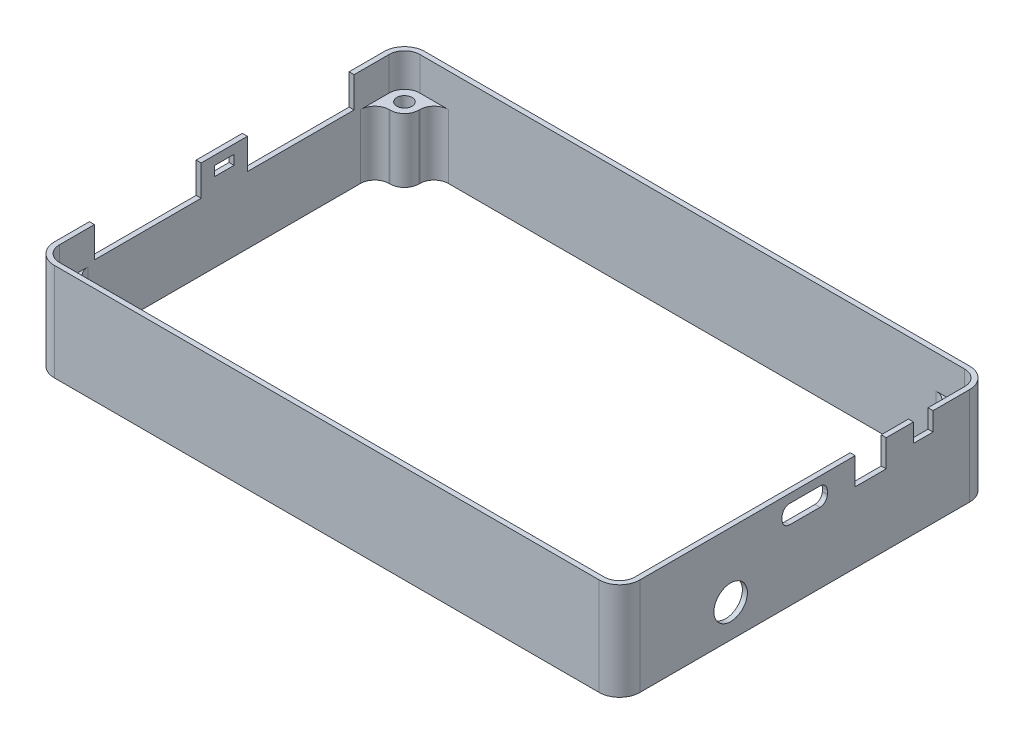
from build123d import *

# Parameters (mm, degrees)
WALLS_DEPTH         = 7
WALLS_DEPTH_BACK    = 13.4
SKETCH11_R          = 1.6
BOSS_EXTRUDE4_DEPTH = 13.4
MOVE_FACE7_BY       = 0.2
MOVE_FACE7_2_BY     = 0.2
MOVE_FACE7_3_BY     = 0.2
MOVE_FACE7_4_BY     = 0.2
MOVE_FACE7_5_BY     = 0.2
MOVE_FACE7_6_BY     = 0.2
MOVE_FACE7_7_BY     = 0.2
MOVE_FACE7_8_BY     = 0.2
FILLET1_R           = 3
SKETCH8_R           = 3.25
SKETCH8_W           = 6
SKETCH8_H           = 5.22
CUT_EXTRUDE3_DEPTH  = 1.05
CUT_EXTRUDE4_REACH  = 131.18
SKETCH10_W          = 20.32
SKETCH10_H          = 5.4
SKETCH10_W_2        = 3.6
SKETCH10_H_2        = 1.5
MOVE_FACE3_BY       = 0.25
MOVE_FACE3_2_BY     = 0.25
MOVE_FACE3_3_BY     = 0.25
MOVE_FACE4_BY       = 0.25
MOVE_FACE4_2_BY     = 0.25
MOVE_FACE4_3_BY     = 0.25
MOVE_FACE4_4_BY     = 0.25
MOVE_FACE4_5_BY     = 0.25
MOVE_FACE4_6_BY     = 0.25
MOVE_FACE4_7_BY     = 0.25
MOVE_FACE4_8_BY     = 0.25
MOVE_FACE4_9_BY     = 0.25
MOVE_FACE4_10_BY    = 0.25
MOVE_FACE4_11_BY    = 0.25
MOVE_FACE4_12_BY    = 0.25
MOVE_FACE4_13_BY    = 0.25
MOVE_FACE1_BY       = 1
MOVE_FACE1_2_BY     = 1
MOVE_FACE1_3_BY     = 1
MOVE_FACE1_4_BY     = 1
MOVE_FACE1_5_BY     = 1
MOVE_FACE1_6_BY     = 1
MOVE_FACE2_BY       = 0.25
MOVE_FACE2_2_BY     = 0.25
MOVE_FACE2_3_BY     = 0.25
MOVE_FACE2_4_BY     = 0.25
SKETCH4_R           = 2.15
BOTTOM_LID_DEPTH    = 3
SKETCH5_R           = 5.5
SKETCH5_R_2         = 1.6
SKETCH5_W           = 7.62
SKETCH5_H           = 2.54
TOP_LID_DEPTH       = 1.6
MOVE_FACE5_BY       = 0.25
MOVE_FACE5_2_BY     = 0.25
MOVE_FACE5_3_BY     = 0.25
MOVE_FACE5_4_BY     = 0.25


with BuildPart() as part:
    # Sketch2 → Walls (new, two sides)
    with BuildSketch(Plane(origin=(0, 0, 0), x_dir=(1, 0, 0), z_dir=(0, 1, 0))) as walls_sk:
        with BuildLine():
            Line((-61.25, -34.5), (-61.25, 34.5))
            ThreePointArc((-61.25, 34.5), (-60.00520382, 37.50520382), (-57, 38.75))
            Line((-57, 38.75), (57, 38.75))
            ThreePointArc((57, 38.75), (60.00520382, 37.50520382), (61.25, 34.5))
            Line((61.25, 34.5), (61.25, -34.5))
            ThreePointArc((61.25, -34.5), (60.00520382, -37.50520382), (57, -38.75))
            Line((57, -38.75), (-57, -38.75))
            ThreePointArc((-57, -38.75), (-60.00520382, -37.50520382), (-61.25, -34.5))
        make_face()
        with BuildLine():
            Line((-60, -34.5), (-60, 34.5))
            ThreePointArc((-60, 34.5), (-59.121320344, 36.621320344), (-57, 37.5))
            Line((-57, 37.5), (57, 37.5))
            ThreePointArc((57, 37.5), (59.121320344, 36.621320344), (60, 34.5))
            Line((60, 34.5), (60, -34.5))
            ThreePointArc((60, -34.5), (59.121320344, -36.621320344), (57, -37.5))
            Line((57, -37.5), (-57, -37.5))
            ThreePointArc((-57, -37.5), (-59.121320344, -36.621320344), (-60, -34.5))
        make_face(mode=Mode.SUBTRACT)
    extrude(amount=WALLS_DEPTH)
    extrude(walls_sk.sketch, amount=-WALLS_DEPTH_BACK)

    # Sketch11 → Boss-Extrude4 (add)
    with BuildSketch(Plane(origin=(0, 0, 0), x_dir=(1, 0, 0), z_dir=(0, 1, 0))):
        with BuildLine():
            Line((-60, -34.5), (-60, -31.5))
            Line((-60, -31.5), (-54, -31.5))
            Line((-54, -31.5), (-54, -37.5))
            Line((-54, -37.5), (-57, -37.5))
            ThreePointArc((-57, -37.5), (-59.121320344, -36.621320344), (-60, -34.5))
        make_face()
        with Locations(Location((-57, -34.5, 0), (0, 0, 270))):
            Circle(SKETCH11_R, mode=Mode.SUBTRACT)
        with BuildLine():
            Line((-57, 37.5), (-54, 37.5))
            Line((-54, 37.5), (-54, 31.5))
            Line((-54, 31.5), (-60, 31.5))
            Line((-60, 31.5), (-60, 34.5))
            ThreePointArc((-60, 34.5), (-59.121320344, 36.621320344), (-57, 37.5))
        make_face()
        with Locations(Location((-57, 34.5, 0), (0, 0, 270))):
            Circle(SKETCH11_R, mode=Mode.SUBTRACT)
        with BuildLine():
            Line((60, -31.5), (54, -31.5))
            Line((54, -31.5), (54, -37.5))
            Line((54, -37.5), (57, -37.5))
            ThreePointArc((57, -37.5), (59.121320344, -36.621320344), (60, -34.5))
            Line((60, -34.5), (60, -31.5))
        make_face()
        with Locations(Location((57, -34.5, 0), (0, 0, 270))):
            Circle(SKETCH11_R, mode=Mode.SUBTRACT)
        with BuildLine():
            Line((57, 37.5), (54, 37.5))
            Line((54, 37.5), (54, 31.5))
            Line((54, 31.5), (60, 31.5))
            Line((60, 31.5), (60, 34.5))
            ThreePointArc((60, 34.5), (59.121320344, 36.621320344), (57, 37.5))
        make_face()
        with Locations(Location((57, 34.5, 0), (0, 0, 270))):
            Circle(SKETCH11_R, mode=Mode.SUBTRACT)
    extrude(amount=-BOSS_EXTRUDE4_DEPTH)

    # Move Face7: a curved face moved inward by 0.2
    add(Solid.thicken(part.faces().sort_by_distance((59.121320344, 3.5, 36.621320344))[0], -MOVE_FACE7_BY), mode=Mode.SUBTRACT)

    # Move Face7 2: a face moved inward by 0.2
    extrude(part.faces().sort_by_distance((60, -2.987974684, 0))[0], amount=MOVE_FACE7_2_BY, dir=(1, 0, 0), mode=Mode.SUBTRACT)

    # Move Face7 3: a curved face moved inward by 0.2
    add(Solid.thicken(part.faces().sort_by_distance((59.121320344, 3.5, -36.621320344))[0], -MOVE_FACE7_3_BY), mode=Mode.SUBTRACT)

    # Move Face7 4: a face moved inward by 0.2
    extrude(part.faces().sort_by_distance((0, -3.074665954, -37.5))[0], amount=MOVE_FACE7_4_BY, dir=(0, 0, -1), mode=Mode.SUBTRACT)

    # Move Face7 5: a curved face moved inward by 0.2
    add(Solid.thicken(part.faces().sort_by_distance((-59.121320344, 3.5, -36.621320344))[0], -MOVE_FACE7_5_BY), mode=Mode.SUBTRACT)

    # Move Face7 6: a face moved inward by 0.2
    extrude(part.faces().sort_by_distance((-60, -2.987974684, 0))[0], amount=MOVE_FACE7_6_BY, dir=(-1, 0, 0), mode=Mode.SUBTRACT)

    # Move Face7 7: a face moved inward by 0.2
    extrude(part.faces().sort_by_distance((0, -3.074665954, 37.5))[0], amount=MOVE_FACE7_7_BY, dir=(0, 0, 1), mode=Mode.SUBTRACT)

    # Move Face7 8: a curved face moved inward by 0.2
    add(Solid.thicken(part.faces().sort_by_distance((-59.121320344, 3.5, 36.621320344))[0], -MOVE_FACE7_8_BY), mode=Mode.SUBTRACT)

    # Fillet1
    fillet1_edges = [part.edges().sort_by_distance(p)[0] for p in [
        (-60.2, -6.7, -31.5),
        (-54, -6.7, -31.5),
        (-54, -6.7, -37.7),
        (54, -6.7, 31.5),
        (54, -6.7, 37.7),
        (60.2, -6.7, 31.5),
        (54, -6.7, -37.7),
        (54, -6.7, -31.5),
        (60.2, -6.7, -31.5),
        (-54, -6.7, 37.7),
        (-54, -6.7, 31.5),
        (-60.2, -6.7, 31.5),
    ]]
    fillet(fillet1_edges, radius=FILLET1_R)

    # Sketch8 → Cut-Extrude3 (cut)
    with BuildSketch(Plane(origin=(61.25, 0, 0), x_dir=(0, 0, -1), z_dir=(1, 0, 0))):
        with Locations((-15.5, -6.55)):
            Circle(SKETCH8_R)
        with BuildLine():
            Line((-3.17, 1.57), (3.17, 1.57))
            ThreePointArc((3.17, 1.57), (4.089238816, 1.950761184), (4.47, 2.87))
            Line((4.47, 2.87), (4.47, 3.63))
            ThreePointArc((4.47, 3.63), (4.089238816, 4.549238816), (3.17, 4.93))
            Line((3.17, 4.93), (-3.17, 4.93))
            ThreePointArc((-3.17, 4.93), (-4.089238816, 4.549238816), (-4.47, 3.63))
            Line((-4.47, 3.63), (-4.47, 2.87))
            ThreePointArc((-4.47, 2.87), (-4.089238816, 1.950761184), (-3.17, 1.57))
        make_face()
        Polygon((23, 4.87), (23, 7), (26.6, 7), (26.6, 4.87), (26.6, 3.37), (23, 3.37), align=None)
        with Locations((13.8, 4.21)):
            Rectangle(SKETCH8_W, SKETCH8_H)
    extrude(amount=-CUT_EXTRUDE3_DEPTH, mode=Mode.SUBTRACT)

    # Sketch10 → Cut-Extrude4 (cut, up to next)
    with BuildSketch(Plane.ZY.offset(61.25), mode=Mode.PRIVATE) as cut_extrude4_sk1:
        with Locations((16, 4.3)):
            Rectangle(SKETCH10_W, SKETCH10_H)
    cut_extrude4_tool1 = extrude(cut_extrude4_sk1.sketch, amount=-CUT_EXTRUDE4_REACH, mode=Mode.PRIVATE) & part.part
    # Sketch10 → Cut-Extrude4 (cut, up to next)
    with BuildSketch(Plane.ZY.offset(61.25), mode=Mode.PRIVATE) as cut_extrude4_sk2:
        with Locations((-16, 4.3)):
            Rectangle(SKETCH10_W, SKETCH10_H)
    cut_extrude4_tool2 = extrude(cut_extrude4_sk2.sketch, amount=-CUT_EXTRUDE4_REACH, mode=Mode.PRIVATE) & part.part
    # Sketch10 → Cut-Extrude4 (cut, up to next)
    with BuildSketch(Plane.ZY.offset(61.25), mode=Mode.PRIVATE) as cut_extrude4_sk3:
        with Locations((0, 4.12)):
            Rectangle(SKETCH10_W_2, SKETCH10_H_2)
    cut_extrude4_tool3 = extrude(cut_extrude4_sk3.sketch, amount=-CUT_EXTRUDE4_REACH, mode=Mode.PRIVATE) & part.part
    add(cut_extrude4_tool1.solids().sort_by_distance((-61.25, 4.3, 16))[0], mode=Mode.SUBTRACT)
    add(cut_extrude4_tool2.solids().sort_by_distance((-61.25, 4.3, -16))[0], mode=Mode.SUBTRACT)
    add(cut_extrude4_tool3.solids().sort_by_distance((-61.25, 4.12, 0))[0], mode=Mode.SUBTRACT)

    # Move Face3: a face moved inward by 0.25
    extrude(part.faces().sort_by_distance((60.725, 5.185, -23))[0], amount=MOVE_FACE3_BY, dir=(0, 0, 1), mode=Mode.SUBTRACT)

    # Move Face3 2: a face moved inward by 0.25
    extrude(part.faces().sort_by_distance((60.725, 5.185, -26.6))[0], amount=MOVE_FACE3_2_BY, dir=(0, 0, -1), mode=Mode.SUBTRACT)

    # Move Face3 3: a face moved inward by 0.25
    extrude(part.faces().sort_by_distance((60.725, 3.37, -24.8))[0], amount=MOVE_FACE3_3_BY, dir=(0, -1, 0), mode=Mode.SUBTRACT)

    # Move Face4: a curved face moved inward by 0.25
    add(Solid.thicken(part.faces().sort_by_distance((60.725, -6.55, 18.75))[0], -MOVE_FACE4_BY), mode=Mode.SUBTRACT)

    # Move Face4 2: a curved face moved inward by 0.25
    add(Solid.thicken(part.faces().sort_by_distance((60.725, 1.950761184, 4.089238816))[0], -MOVE_FACE4_2_BY), mode=Mode.SUBTRACT)

    # Move Face4 3: a face moved inward by 0.25
    extrude(part.faces().sort_by_distance((60.725, 3.25, 4.47))[0], amount=MOVE_FACE4_3_BY, dir=(0, 0, 1), mode=Mode.SUBTRACT)

    # Move Face4 4: a curved face moved inward by 0.25
    add(Solid.thicken(part.faces().sort_by_distance((60.725, 4.549238816, 4.089238816))[0], -MOVE_FACE4_4_BY), mode=Mode.SUBTRACT)

    # Move Face4 5: a face moved inward by 0.25
    extrude(part.faces().sort_by_distance((60.725, 4.93, 0))[0], amount=MOVE_FACE4_5_BY, dir=(0, 1, 0), mode=Mode.SUBTRACT)

    # Move Face4 6: a curved face moved inward by 0.25
    add(Solid.thicken(part.faces().sort_by_distance((60.725, 1.950761184, -4.089238816))[0], -MOVE_FACE4_6_BY), mode=Mode.SUBTRACT)

    # Move Face4 7: a face moved inward by 0.25
    extrude(part.faces().sort_by_distance((60.725, 1.57, 0))[0], amount=MOVE_FACE4_7_BY, dir=(0, -1, 0), mode=Mode.SUBTRACT)

    # Move Face4 8: a face moved inward by 0.25
    extrude(part.faces().sort_by_distance((60.725, 3.25, -4.47))[0], amount=MOVE_FACE4_8_BY, dir=(0, 0, -1), mode=Mode.SUBTRACT)

    # Move Face4 9: a curved face moved inward by 0.25
    add(Solid.thicken(part.faces().sort_by_distance((60.725, 4.549238816, -4.089238816))[0], -MOVE_FACE4_9_BY), mode=Mode.SUBTRACT)

    # Move Face4 10: a face moved inward by 0.25
    extrude(part.faces().sort_by_distance((60.725, 1.6, -13.8))[0], amount=MOVE_FACE4_10_BY, dir=(0, -1, 0), mode=Mode.SUBTRACT)

    # Move Face4 11: a face moved inward by 0.25
    extrude(part.faces().sort_by_distance((60.725, 4.21, -16.8))[0], amount=MOVE_FACE4_11_BY, dir=(0, 0, -1), mode=Mode.SUBTRACT)

    # Move Face4 12: a face moved inward by 0.25
    extrude(part.faces().sort_by_distance((60.725, 4.21, -10.8))[0], amount=MOVE_FACE4_12_BY, dir=(0, 0, 1), mode=Mode.SUBTRACT)

    # Move Face4 13: a face moved inward by 0.25
    extrude(part.faces().sort_by_distance((60.725, 6.82, -13.8))[0], amount=MOVE_FACE4_13_BY, dir=(0, 1, 0), mode=Mode.SUBTRACT)

    # Move Face1: a face moved inward by 1.0
    extrude(part.faces().sort_by_distance((-60.725, 4.3, 26.16))[0], amount=MOVE_FACE1_BY, dir=(0, 0, 1), mode=Mode.SUBTRACT)

    # Move Face1 2: a face moved inward by 1.0
    extrude(part.faces().sort_by_distance((-60.725, 1.6, 16))[0], amount=MOVE_FACE1_2_BY, dir=(0, -1, 0), mode=Mode.SUBTRACT)

    # Move Face1 3: a face moved inward by 1.0
    extrude(part.faces().sort_by_distance((-60.725, 4.3, 5.84))[0], amount=MOVE_FACE1_3_BY, dir=(0, 0, -1), mode=Mode.SUBTRACT)

    # Move Face1 4: a face moved inward by 1.0
    extrude(part.faces().sort_by_distance((-60.725, 4.3, -26.16))[0], amount=MOVE_FACE1_4_BY, dir=(0, 0, -1), mode=Mode.SUBTRACT)

    # Move Face1 5: a face moved inward by 1.0
    extrude(part.faces().sort_by_distance((-60.725, 1.6, -16))[0], amount=MOVE_FACE1_5_BY, dir=(0, -1, 0), mode=Mode.SUBTRACT)

    # Move Face1 6: a face moved inward by 1.0
    extrude(part.faces().sort_by_distance((-60.725, 4.3, -5.84))[0], amount=MOVE_FACE1_6_BY, dir=(0, 0, 1), mode=Mode.SUBTRACT)

    # Move Face2: a face moved inward by 0.25
    extrude(part.faces().sort_by_distance((-60.725, 4.12, -1.8))[0], amount=MOVE_FACE2_BY, dir=(0, 0, -1), mode=Mode.SUBTRACT)

    # Move Face2 2: a face moved inward by 0.25
    extrude(part.faces().sort_by_distance((-60.725, 4.87, 0))[0], amount=MOVE_FACE2_2_BY, dir=(0, 1, 0), mode=Mode.SUBTRACT)

    # Move Face2 3: a face moved inward by 0.25
    extrude(part.faces().sort_by_distance((-60.725, 3.37, 0))[0], amount=MOVE_FACE2_3_BY, dir=(0, -1, 0), mode=Mode.SUBTRACT)

    # Move Face2 4: a face moved inward by 0.25
    extrude(part.faces().sort_by_distance((-60.725, 4.12, 1.8))[0], amount=MOVE_FACE2_4_BY, dir=(0, 0, 1), mode=Mode.SUBTRACT)


with BuildPart() as body_2:
    # Sketch4 → Bottom Lid (new body)
    with BuildSketch(Plane.XZ.offset(13.4)):
        with BuildLine():
            Line((-57, -38.75), (57, -38.75))
            ThreePointArc((57, -38.75), (60.00520382, -37.50520382), (61.25, -34.5))
            Line((61.25, -34.5), (61.25, 34.5))
            ThreePointArc((61.25, 34.5), (60.00520382, 37.50520382), (57, 38.75))
            Line((57, 38.75), (-57, 38.75))
            ThreePointArc((-57, 38.75), (-60.00520382, 37.50520382), (-61.25, 34.5))
            Line((-61.25, 34.5), (-61.25, -34.5))
            ThreePointArc((-61.25, -34.5), (-60.00520382, -37.50520382), (-57, -38.75))
        make_face()
        with Locations(Location((57, -34.5, 0), (0, 0, 270))):
            Circle(SKETCH4_R, mode=Mode.SUBTRACT)
        with Locations(Location((-57, -34.5, 0), (0, 0, 270))):
            Circle(SKETCH4_R, mode=Mode.SUBTRACT)
        with Locations(Location((-57, 34.5, 0), (0, 0, 270))):
            Circle(SKETCH4_R, mode=Mode.SUBTRACT)
        with Locations(Location((57, 34.5, 0), (0, 0, 270))):
            Circle(SKETCH4_R, mode=Mode.SUBTRACT)
    extrude(amount=BOTTOM_LID_DEPTH)


with BuildPart() as body_3:
    # Sketch5 → Top Lid (new body)
    with BuildSketch(Plane(origin=(0, 7, 0), x_dir=(1, 0, 0), z_dir=(0, 1, 0))):
        with BuildLine():
            Line((57, 38.75), (-57, 38.75))
            ThreePointArc((-57, 38.75), (-60.00520382, 37.50520382), (-61.25, 34.5))
            Line((-61.25, 34.5), (-61.25, -34.5))
            ThreePointArc((-61.25, -34.5), (-60.00520382, -37.50520382), (-57, -38.75))
            Line((-57, -38.75), (57, -38.75))
            ThreePointArc((57, -38.75), (60.00520382, -37.50520382), (61.25, -34.5))
            Line((61.25, -34.5), (61.25, 34.5))
            ThreePointArc((61.25, 34.5), (60.00520382, 37.50520382), (57, 38.75))
        make_face()
        with Locations(Location((42, 27.5, 0), (0, 0, 270))):
            Circle(SKETCH5_R, mode=Mode.SUBTRACT)
        with Locations(Location((-14, 27.5, 0), (0, 0, 270))):
            Circle(SKETCH5_R, mode=Mode.SUBTRACT)
        with Locations(Location((14, 27.5, 0), (0, 0, 270))):
            Circle(SKETCH5_R, mode=Mode.SUBTRACT)
        with Locations(Location((-42, 27.5, 0), (0, 0, 270))):
            Circle(SKETCH5_R, mode=Mode.SUBTRACT)
        with Locations(Location((42, -27.5, 0), (0, 0, 270))):
            Circle(SKETCH5_R, mode=Mode.SUBTRACT)
        with Locations(Location((14, -27.5, 0), (0, 0, 270))):
            Circle(SKETCH5_R, mode=Mode.SUBTRACT)
        with Locations(Location((-14, -27.5, 0), (0, 0, 270))):
            Circle(SKETCH5_R, mode=Mode.SUBTRACT)
        with Locations(Location((-42, -27.5, 0), (0, 0, 270))):
            Circle(SKETCH5_R, mode=Mode.SUBTRACT)
        with Locations(Location((-57, -34.5, 0), (0, 0, 270))):
            Circle(SKETCH5_R_2, mode=Mode.SUBTRACT)
        with Locations(Location((-57, 34.5, 0), (0, 0, 270))):
            Circle(SKETCH5_R_2, mode=Mode.SUBTRACT)
        with Locations(Location((57, 34.5, 0), (0, 0, 270))):
            Circle(SKETCH5_R_2, mode=Mode.SUBTRACT)
        with Locations(Location((57, -34.5, 0), (0, 0, 270))):
            Circle(SKETCH5_R_2, mode=Mode.SUBTRACT)
        with Locations((6.24, 11.2375)):
            Rectangle(SKETCH5_W, SKETCH5_H, mode=Mode.SUBTRACT)
    extrude(amount=TOP_LID_DEPTH)

    # Move Face5: a face moved inward by 0.25
    extrude(body_3.faces().sort_by_distance((2.43, 7.8, -11.2375))[0], amount=MOVE_FACE5_BY, dir=(-1, 0, 0), mode=Mode.SUBTRACT)

    # Move Face5 2: a face moved inward by 0.25
    extrude(body_3.faces().sort_by_distance((6.24, 7.8, -9.9675))[0], amount=MOVE_FACE5_2_BY, dir=(0, 0, 1), mode=Mode.SUBTRACT)

    # Move Face5 3: a face moved inward by 0.25
    extrude(body_3.faces().sort_by_distance((10.05, 7.8, -11.2375))[0], amount=MOVE_FACE5_3_BY, dir=(1, 0, 0), mode=Mode.SUBTRACT)

    # Move Face5 4: a face moved inward by 0.25
    extrude(body_3.faces().sort_by_distance((6.24, 7.8, -12.5075))[0], amount=MOVE_FACE5_4_BY, dir=(0, 0, -1), mode=Mode.SUBTRACT)


solid = part.part
